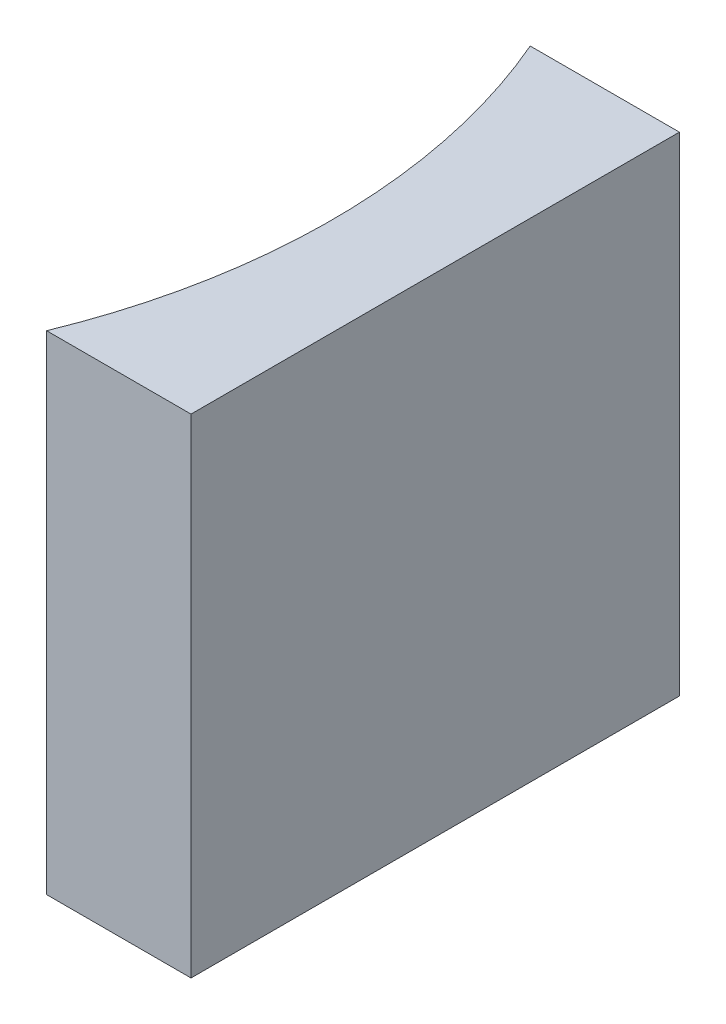
from build123d import *

# Parameters (mm, degrees)
EXTRUDE_1_DEPTH = 10


with BuildPart() as part:
    # 草图1 → 凸台-拉伸1 (new body)
    with BuildSketch(Plane(origin=(0, 0, 0), x_dir=(1, 0, 0), z_dir=(0, 1, 0))):
        with BuildLine():
            Line((0, 0), (0, -10))
            Line((0, -10), (-2.957014408, -10))
            ThreePointArc((-2.957014408, -10), (-1.999975821, -4.990165604), (-3.054779492, 0))
            Line((-3.054779492, 0), (0, 0))
        make_face()
    extrude(amount=EXTRUDE_1_DEPTH)


solid = part.part
